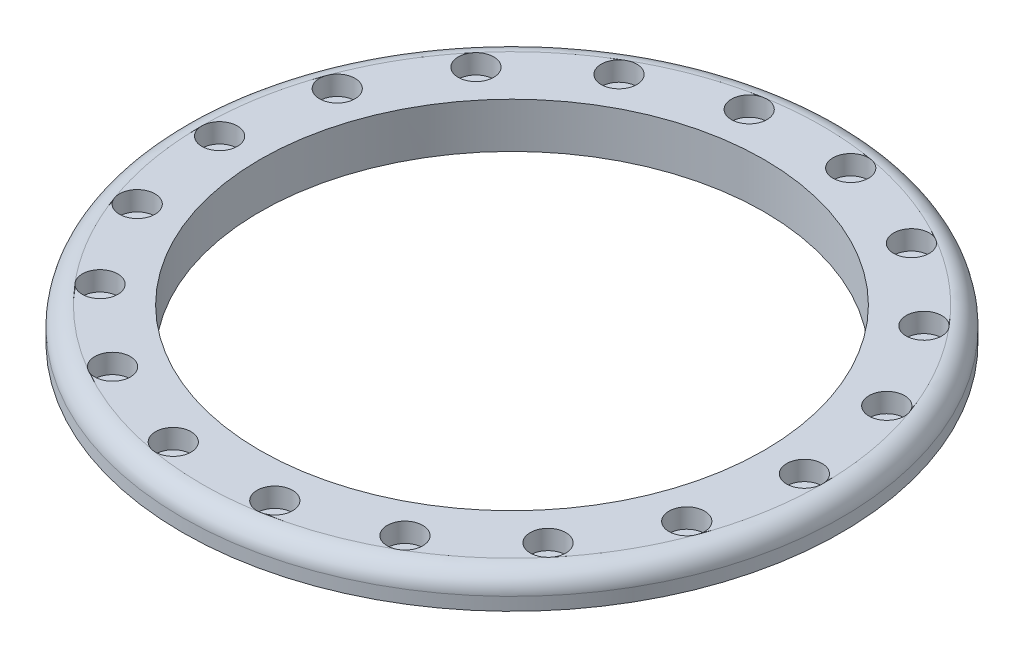
from build123d import *

# Parameters (mm, degrees)
SKETCH1_R           = 51
SKETCH1_R_2         = 39
SKETCH1_R_3         = 1.5
BOSS_EXTRUDE1_DEPTH = 5
FILLET1_R           = 3
SKETCH2_R           = 2.75
CUT_EXTRUDE1_DEPTH  = 3
SKETCH3_R           = 41.5
SKETCH3_R_2         = 39
BOSS_EXTRUDE2_DEPTH = 2


with BuildPart() as part:
    # Sketch1 → Boss-Extrude1 (new body)
    with BuildSketch(Plane(origin=(0, 0, 0), x_dir=(1, 0, 0), z_dir=(0, 1, 0))):
        Circle(SKETCH1_R)
        Circle(SKETCH1_R_2, mode=Mode.SUBTRACT)
        with Locations((45.25, 0)):
            Circle(SKETCH1_R_3, mode=Mode.SUBTRACT)
        with Locations((42.521091091, -15.476411485)):
            Circle(SKETCH1_R_3, mode=Mode.SUBTRACT)
        with Locations((34.663511051, -29.086139338)):
            Circle(SKETCH1_R_3, mode=Mode.SUBTRACT)
        with Locations((22.625, -39.187649521)):
            Circle(SKETCH1_R_3, mode=Mode.SUBTRACT)
        with Locations((7.857580039, -44.562550824)):
            Circle(SKETCH1_R_3, mode=Mode.SUBTRACT)
        with Locations((-7.857580039, -44.562550824)):
            Circle(SKETCH1_R_3, mode=Mode.SUBTRACT)
        with Locations((-22.625, -39.187649521)):
            Circle(SKETCH1_R_3, mode=Mode.SUBTRACT)
        with Locations((-34.663511051, -29.086139338)):
            Circle(SKETCH1_R_3, mode=Mode.SUBTRACT)
        with Locations((-42.521091091, -15.476411485)):
            Circle(SKETCH1_R_3, mode=Mode.SUBTRACT)
        with Locations((-45.25, 0)):
            Circle(SKETCH1_R_3, mode=Mode.SUBTRACT)
        with Locations((-42.521091091, 15.476411485)):
            Circle(SKETCH1_R_3, mode=Mode.SUBTRACT)
        with Locations((-34.663511051, 29.086139338)):
            Circle(SKETCH1_R_3, mode=Mode.SUBTRACT)
        with Locations((-22.625, 39.187649521)):
            Circle(SKETCH1_R_3, mode=Mode.SUBTRACT)
        with Locations((-7.857580039, 44.562550824)):
            Circle(SKETCH1_R_3, mode=Mode.SUBTRACT)
        with Locations((7.857580039, 44.562550824)):
            Circle(SKETCH1_R_3, mode=Mode.SUBTRACT)
        with Locations((22.625, 39.187649521)):
            Circle(SKETCH1_R_3, mode=Mode.SUBTRACT)
        with Locations((34.663511051, 29.086139338)):
            Circle(SKETCH1_R_3, mode=Mode.SUBTRACT)
        with Locations((42.521091091, 15.476411485)):
            Circle(SKETCH1_R_3, mode=Mode.SUBTRACT)
    extrude(amount=BOSS_EXTRUDE1_DEPTH)

    # Fillet1
    fillet1_edges = [part.edges().sort_by_distance(p)[0] for p in [
        (-51, 5, 0),
    ]]
    fillet(fillet1_edges, radius=FILLET1_R)

    # Sketch2 → Cut-Extrude1 (cut)
    with BuildSketch(Plane(origin=(0, 5, 0), x_dir=(1, 0, 0), z_dir=(0, 1, 0))):
        with Locations((45.25, 0)):
            Circle(SKETCH2_R)
        with Locations((42.521091091, -15.476411485)):
            Circle(SKETCH2_R)
        with Locations((34.663511051, -29.086139338)):
            Circle(SKETCH2_R)
        with Locations((22.625, -39.187649521)):
            Circle(SKETCH2_R)
        with Locations((7.857580039, -44.562550824)):
            Circle(SKETCH2_R)
        with Locations((-7.857580039, -44.562550824)):
            Circle(SKETCH2_R)
        with Locations((-22.625, -39.187649521)):
            Circle(SKETCH2_R)
        with Locations((-34.663511051, -29.086139338)):
            Circle(SKETCH2_R)
        with Locations((-42.521091091, -15.476411485)):
            Circle(SKETCH2_R)
        with Locations((-45.25, 0)):
            Circle(SKETCH2_R)
        with Locations((-42.521091091, 15.476411485)):
            Circle(SKETCH2_R)
        with Locations((-34.663511051, 29.086139338)):
            Circle(SKETCH2_R)
        with Locations((-22.625, 39.187649521)):
            Circle(SKETCH2_R)
        with Locations((-7.857580039, 44.562550824)):
            Circle(SKETCH2_R)
        with Locations((7.857580039, 44.562550824)):
            Circle(SKETCH2_R)
        with Locations((22.625, 39.187649521)):
            Circle(SKETCH2_R)
        with Locations((34.663511051, 29.086139338)):
            Circle(SKETCH2_R)
        with Locations((42.521091091, 15.476411485)):
            Circle(SKETCH2_R)
    extrude(amount=-CUT_EXTRUDE1_DEPTH, mode=Mode.SUBTRACT)

    # Sketch3 → Boss-Extrude2 (add)
    with BuildSketch(Plane.XZ):
        Circle(SKETCH3_R)
        Circle(SKETCH3_R_2, mode=Mode.SUBTRACT)
    extrude(amount=BOSS_EXTRUDE2_DEPTH)


solid = part.part
